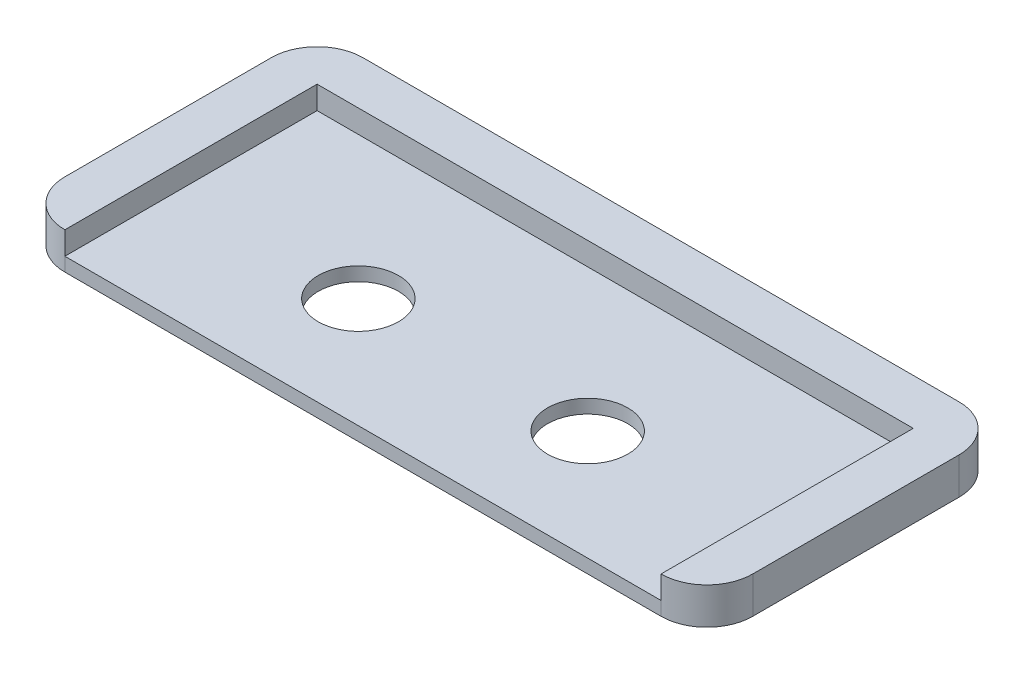
from build123d import *

# Parameters (mm, degrees)
SKETCH1_W           = 30
SKETCH1_H           = 13
BOSS_EXTRUDE1_DEPTH = 0.6
BOSS_EXTRUDE2_DEPTH = 1
FILLET1_R           = 2
SKETCH3_R           = 1.75
CUT_EXTRUDE1_DEPTH  = 2.6


with BuildPart() as part:
    # Sketch1 → Boss-Extrude1 (new body)
    with BuildSketch(Plane(origin=(0, 0, 0), x_dir=(1, 0, 0), z_dir=(0, 1, 0))):
        Rectangle(SKETCH1_W, SKETCH1_H)
    extrude(amount=BOSS_EXTRUDE1_DEPTH)

    # Sketch2 → Boss-Extrude2 (add)
    with BuildSketch(Plane(origin=(0, 0.6, 0), x_dir=(1, 0, 0), z_dir=(0, 1, 0))):
        Polygon((-13, 4.5), (13, 4.5), (13, -6.5), (15, -6.5), (15, 6.5), (-15, 6.5), (-15, -6.5), (-13, -6.5), align=None)
    extrude(amount=BOSS_EXTRUDE2_DEPTH)

    # Fillet1
    fillet1_edges = [part.edges().sort_by_distance(p)[0] for p in [
        (-15, 0.8, 6.5),
        (15, 0.8, 6.5),
        (15, 0.8, -6.5),
        (-15, 0.8, -6.5),
    ]]
    fillet(fillet1_edges, radius=FILLET1_R)

    # Sketch3 → Cut-Extrude1 (cut, through all)
    with BuildSketch(Plane.XZ):
        with Locations((-5, 1.7)):
            Circle(SKETCH3_R)
        with Locations((5, 1.7)):
            Circle(SKETCH3_R)
    extrude(amount=-CUT_EXTRUDE1_DEPTH, mode=Mode.SUBTRACT)


solid = part.part
